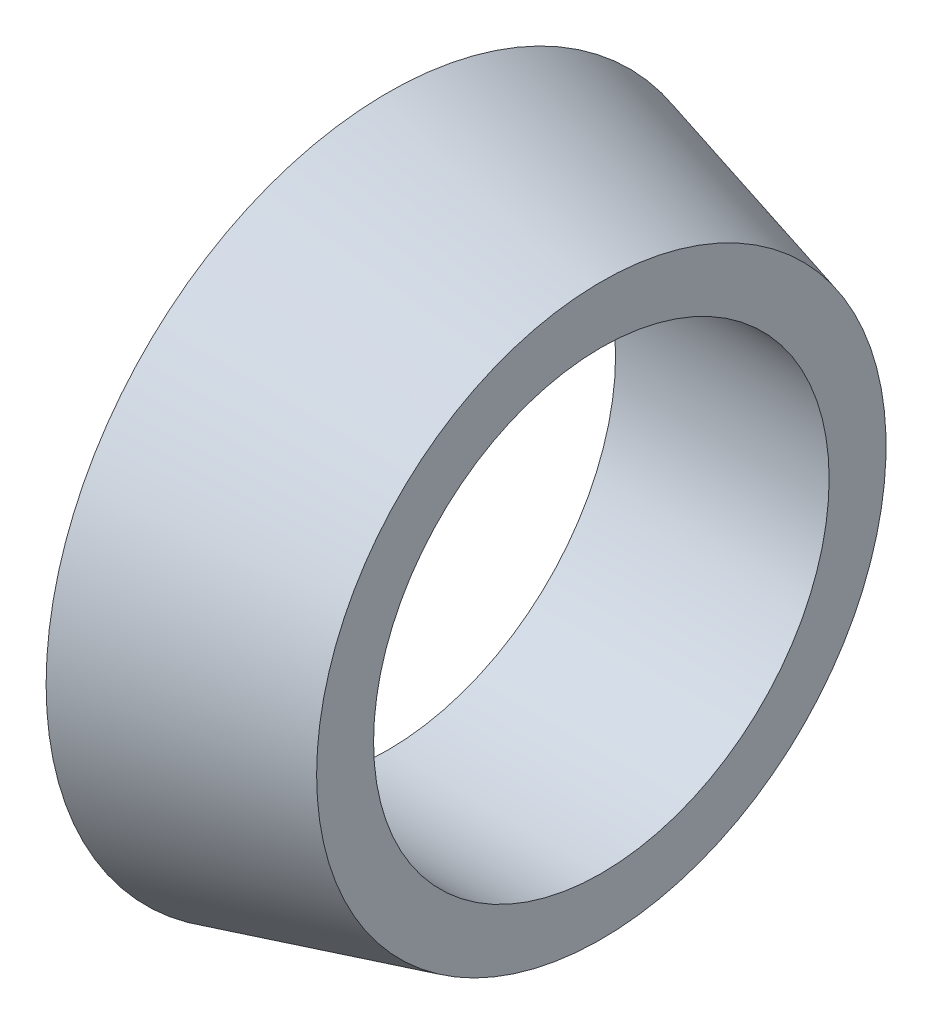
from build123d import *


with BuildPart() as part:
    # Szkic1 → Obrót1 (revolve)
    with BuildSketch(Plane.XY):
        Polygon((0, 4), (0, 6), (3.75, 5), (3.75, 4), align=None)
    revolve(axis=Axis((0, 0, 0), (1, 0, 0)))


solid = part.part
